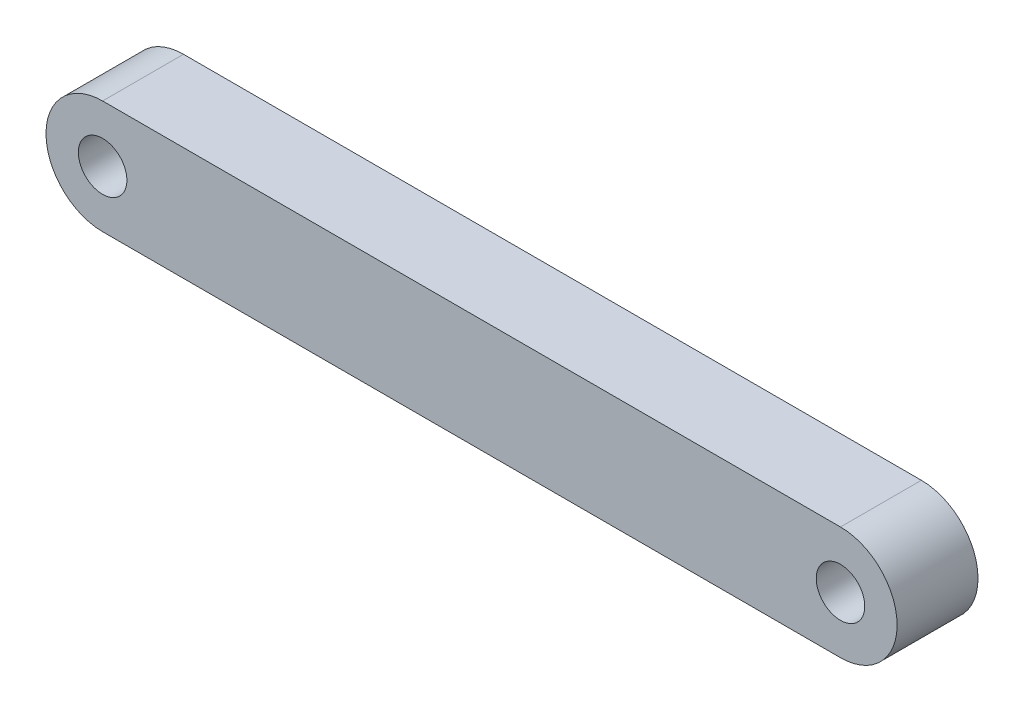
from build123d import *

# Parameters (mm, degrees)
SKETCH1_R           = 1.5
BOSS_EXTRUDE1_DEPTH = 5


with BuildPart() as part:
    # Sketch1 → Boss-Extrude1 (new body)
    with BuildSketch(Plane.XY):
        with BuildLine():
            Line((-45.61, -3.5), (0, -3.5))
            ThreePointArc((0, -3.5), (3.5, 0), (0, 3.5))
            Line((0, 3.5), (-45.61, 3.5))
            ThreePointArc((-45.61, 3.5), (-49.11, 0), (-45.61, -3.5))
        make_face()
        with Locations((-45.61, 0)):
            Circle(SKETCH1_R, mode=Mode.SUBTRACT)
        Circle(SKETCH1_R, mode=Mode.SUBTRACT)
    extrude(amount=BOSS_EXTRUDE1_DEPTH)


solid = part.part
